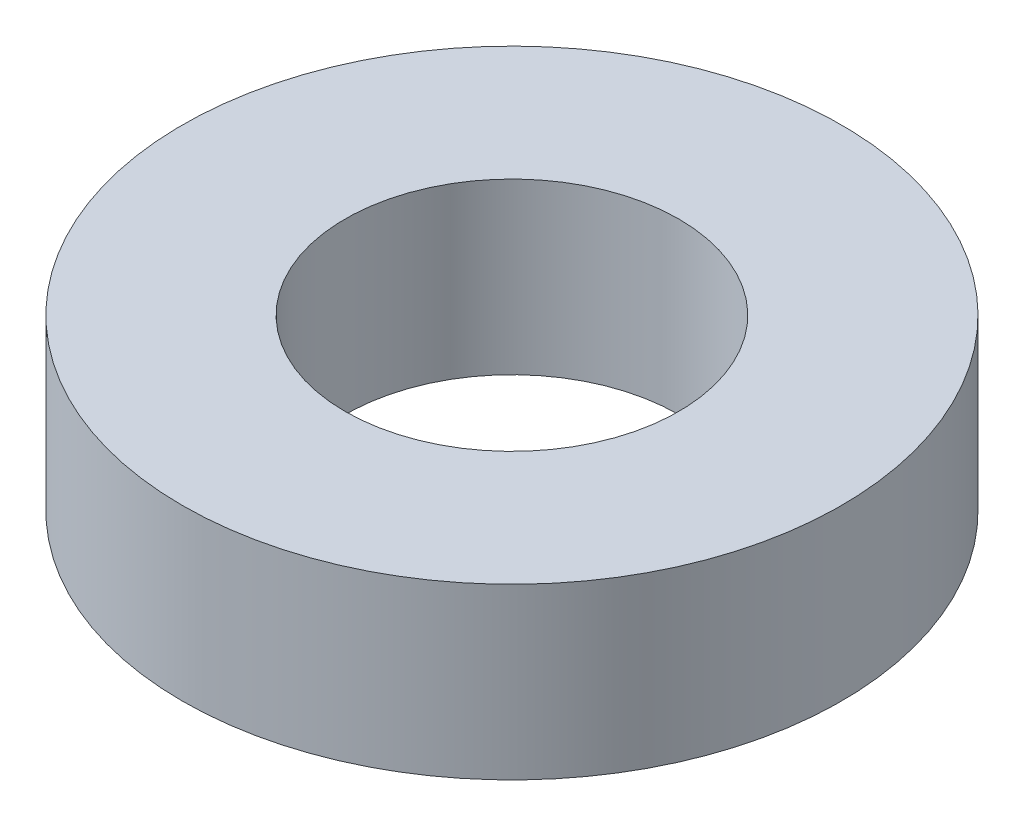
from build123d import *

# Parameters (mm, degrees)
SKETCH1_R           = 24.7
SKETCH1_R_2         = 12.5
BOSS_EXTRUDE1_DEPTH = 12.7


with BuildPart() as part:
    # Sketch1 → Boss-Extrude1 (new body)
    with BuildSketch(Plane(origin=(0, 0, 0), x_dir=(1, 0, 0), z_dir=(0, 1, 0))):
        Circle(SKETCH1_R)
        Circle(SKETCH1_R_2, mode=Mode.SUBTRACT)
    extrude(amount=-BOSS_EXTRUDE1_DEPTH)


solid = part.part
